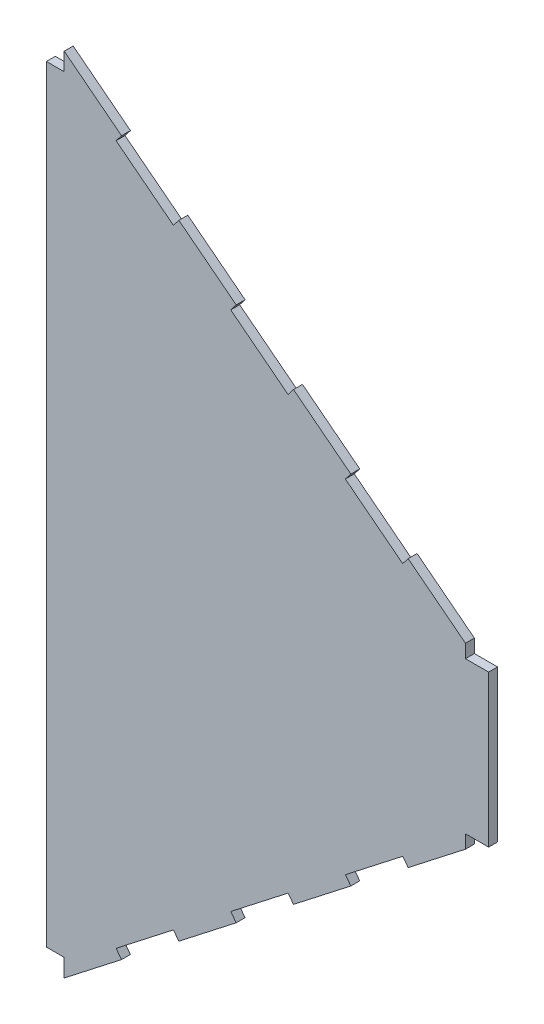
from build123d import *

# Parameters (mm, degrees)
BOSS_EXTRU_1_DEPTH = 5


with BuildPart() as part:
    # Esquisse1 → Boss.-Extru.1 (new body)
    with BuildSketch(Plane.XY):
        Polygon((0, 0), (0, 10), (-10, 10), (-10, 440), (0, 440), (0, 450), (32.134919655, 425), (29.064744216, 421.053606358), (61.199663871, 396.053606358), (64.26983931, 400), (96.404758965, 375), (93.334583526, 371.053606358), (125.469503181, 346.053606358), (128.539678619, 350), (160.674598274, 325), (157.604422836, 321.053606358), (189.739342491, 296.053606358), (192.809517929, 300), (224.944437584, 275), (224.944437584, 267.5), (237.944437584, 267.5), (237.944437584, 182.5), (224.944437584, 182.5), (224.944437584, 175), (192.809517929, 150), (189.739342491, 153.946393642), (157.604422836, 128.946393642), (160.674598274, 125), (128.539678619, 100), (125.469503181, 103.946393642), (93.334583526, 78.946393642), (96.404758965, 75), (64.26983931, 50), (61.199663871, 53.946393642), (29.064744216, 28.946393642), (32.134919655, 25), align=None)
    extrude(amount=BOSS_EXTRU_1_DEPTH)


solid = part.part
